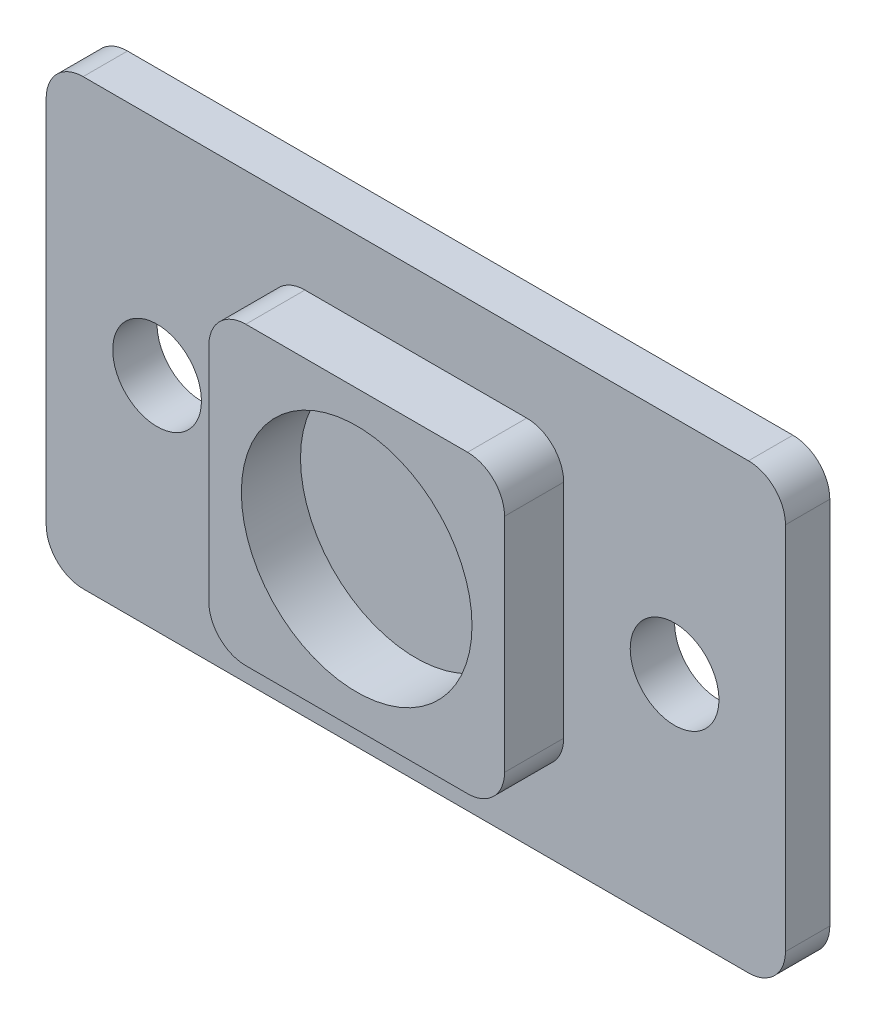
from build123d import *

# Parameters (mm, degrees)
SKETCH1_W           = 50
SKETCH1_H           = 30
SKETCH1_R           = 3
BOSS_EXTRUDE1_DEPTH = 1.5
FILLET1_R           = 2.5
SKETCH2_R           = 7.8
BOSS_EXTRUDE2_DEPTH = 4


with BuildPart() as part:
    # Sketch1 → Boss-Extrude1 (new body, symmetric)
    with BuildSketch(Plane.XY):
        Rectangle(SKETCH1_W, SKETCH1_H)
        with Locations((-17.5, 0)):
            Circle(SKETCH1_R, mode=Mode.SUBTRACT)
        with Locations((17.5, 0)):
            Circle(SKETCH1_R, mode=Mode.SUBTRACT)
    extrude(amount=BOSS_EXTRUDE1_DEPTH, both=True)

    # Fillet1
    fillet1_edges = [part.edges().sort_by_distance(p)[0] for p in [
        (-25, 15, 0),
        (25, 15, 0),
        (25, -15, 0),
        (-25, -15, 0),
    ]]
    fillet(fillet1_edges, radius=FILLET1_R)

    # Sketch2 → Boss-Extrude2 (add)
    with BuildSketch(Plane.XY.offset(1.5)):
        with BuildLine():
            Line((7.5, -10), (-7.5, -10))
            ThreePointArc((-7.5, -10), (-9.267766953, -9.267766953), (-10, -7.5))
            Line((-10, -7.5), (-10, 7.5))
            ThreePointArc((-10, 7.5), (-9.267766953, 9.267766953), (-7.5, 10))
            Line((-7.5, 10), (7.5, 10))
            ThreePointArc((7.5, 10), (9.267766953, 9.267766953), (10, 7.5))
            Line((10, 7.5), (10, -7.5))
            ThreePointArc((10, -7.5), (9.267766953, -9.267766953), (7.5, -10))
        make_face()
        Circle(SKETCH2_R, mode=Mode.SUBTRACT)
    extrude(amount=BOSS_EXTRUDE2_DEPTH)


solid = part.part
